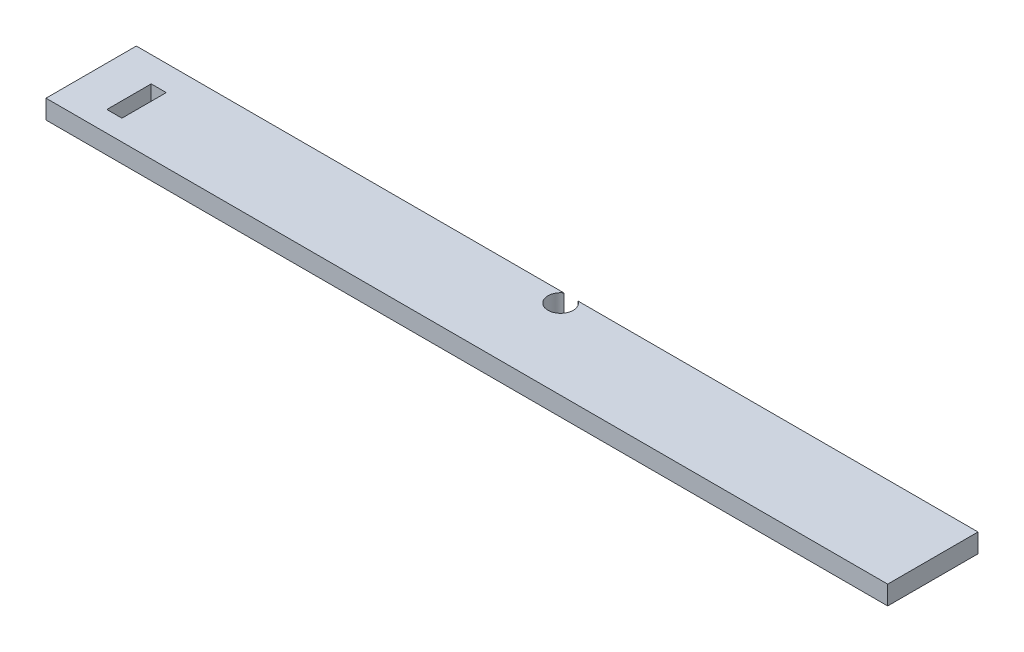
from build123d import *

# Parameters (mm, degrees)
SKETCH1_W           = 846.328
SKETCH1_H           = 90.8304
BOSS_EXTRUDE1_DEPTH = 19.05
SKETCH2_R           = 12.7
CUT_EXTRUDE4_DEPTH  = 20.05
SKETCH4_W           = 15.156731747
SKETCH4_H           = 44.578622786
CUT_EXTRUDE5_DEPTH  = 20.05


with BuildPart() as part:
    # Sketch1 → Boss-Extrude1 (new body)
    with BuildSketch(Plane(origin=(0, 0, 0), x_dir=(1, 0, 0), z_dir=(0, 1, 0))):
        with Locations((423.164, 45.4152)):
            Rectangle(SKETCH1_W, SKETCH1_H)
    extrude(amount=BOSS_EXTRUDE1_DEPTH)

    # Sketch2 → Cut-Extrude4 (cut, through all)
    with BuildSketch(Plane.XZ):
        with Locations((437.1086, -80.3402)):
            Circle(SKETCH2_R)
    extrude(amount=-CUT_EXTRUDE4_DEPTH, mode=Mode.SUBTRACT)

    # Sketch4 → Cut-Extrude5 (cut, through all)
    with BuildSketch(Plane.XZ):
        with Locations((48.024327766, -43.050866134)):
            Rectangle(SKETCH4_W, SKETCH4_H)
    extrude(amount=-CUT_EXTRUDE5_DEPTH, mode=Mode.SUBTRACT)


solid = part.part
